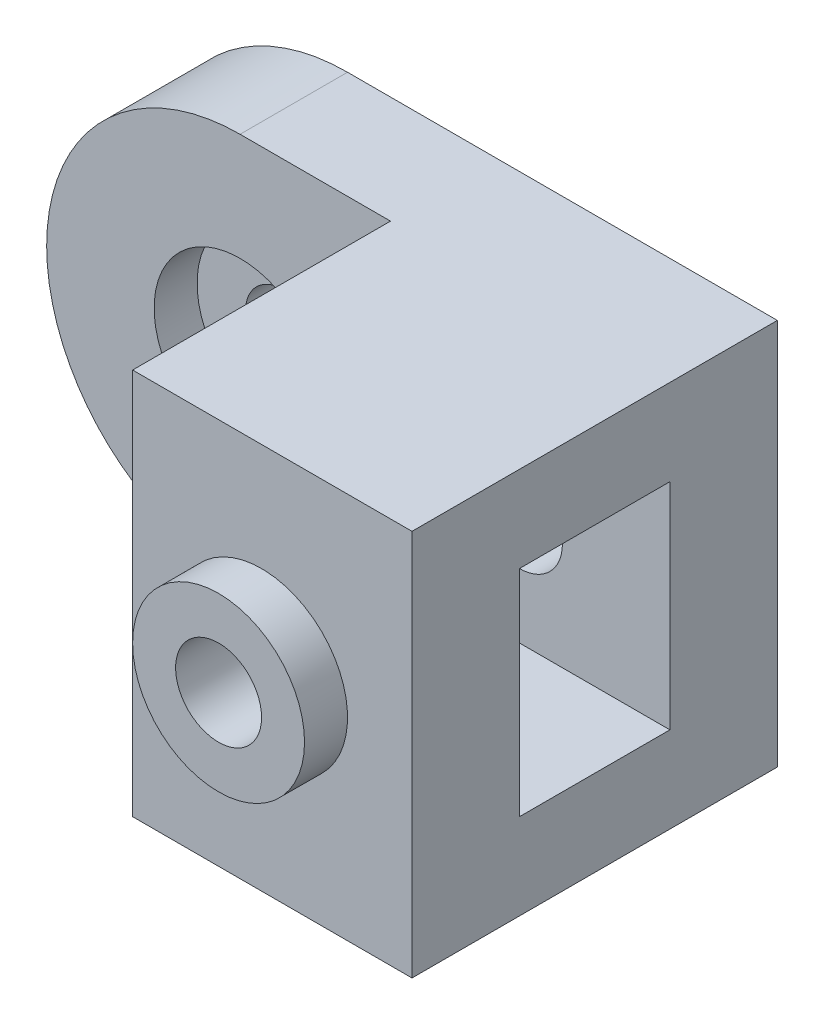
from build123d import *

# Parameters (mm, degrees)
SKETCH1_W                   = 145
SKETCH1_H                   = 90
BOSS_EXTRUDE1_DEPTH         = 85
CUT_EXTRUDE1_DEPTH          = 85
CUT_EXTRUDE3_DEPTH          = 50
M20_TAPPED_HOLE1_AT_2_COUNT = 2
M20_TAPPED_HOLE1_AT_2_PITCH = 65
M20_TAPPED_HOLE3_D          = 17.5
M20_TAPPED_HOLE3_DEPTH      = 60
M20_TAPPED_HOLE3_TIP        = 5.257530416
SKETCH12_R                  = 20
SKETCH12_R_2                = 10
CUT_EXTRUDE4_DEPTH          = 10
SKETCH13_R                  = 10
SKETCH13_R_2                = 8.75
CUT_EXTRUDE5_DEPTH          = 10
CUT_EXTRUDE6_DEPTH          = 10
SKETCH15_R                  = 20
SKETCH15_R_2                = 10
CUT_EXTRUDE7_DEPTH          = 10
SKETCH16_R                  = 10
SKETCH16_R_2                = 8.75
CUT_EXTRUDE8_DEPTH          = 10
SKETCH17_W                  = 35
SKETCH17_H                  = 50
CUT_EXTRUDE9_DEPTH          = 97
SKETCH18_R                  = 20
SKETCH18_R_2                = 10
BOSS_EXTRUDE2_DEPTH         = 10
SKETCH19_R                  = 20
SKETCH19_R_2                = 8.75
BOSS_EXTRUDE3_DEPTH         = 10
SKETCH20_R                  = 10
SKETCH20_R_2                = 8.75
CUT_EXTRUDE10_DEPTH         = 120


with BuildPart() as part:
    # Sketch1 → Boss-Extrude1 (new body)
    with BuildSketch(Plane.XY):
        with Locations((72.5, 45)):
            Rectangle(SKETCH1_W, SKETCH1_H)
    extrude(amount=BOSS_EXTRUDE1_DEPTH)

    # Sketch2 → Cut-Extrude1 (cut)
    with BuildSketch(Plane.XY.offset(85)):
        with BuildLine():
            ThreePointArc((0, 45), (13.180194847, 76.819805153), (45, 90))
            Line((45, 90), (0, 90))
            Line((0, 90), (0, 45))
        make_face()
        with BuildLine():
            ThreePointArc((45, 0), (13.180194847, 13.180194847), (0, 45))
            Line((0, 45), (0, 0))
            Line((0, 0), (45, 0))
        make_face()
    extrude(amount=-CUT_EXTRUDE1_DEPTH, mode=Mode.SUBTRACT)

    # Sketch4 → Cut-Extrude3 (cut)
    with BuildSketch(Plane.XY.offset(85)):
        with BuildLine():
            Line((80, 0), (80, 90))
            Line((80, 90), (45, 90))
            ThreePointArc((45, 90), (0, 45), (45, 0))
            Line((45, 0), (80, 0))
        make_face()
    extrude(amount=-CUT_EXTRUDE3_DEPTH, mode=Mode.SUBTRACT)

    # Sketch6 → M20 Tapped Hole1 (revolve, cut)
    with BuildSketch(Plane(origin=(45, 45, 35), x_dir=(0, -1, 0), z_dir=(1, 0, 0))):
        Polygon((0, 0), (0, 45.257530416), (8.75, 40), (8.75, 0), align=None)
    m20_tapped_hole1 = revolve(axis=Axis((45, 45, 41.35), (0, 0, -1)), mode=Mode.SUBTRACT)

    # M20 Tapped Hole1 at 2: M20 Tapped Hole1 ×2
    with Locations(*[(i * M20_TAPPED_HOLE1_AT_2_PITCH, 0, 0) for i in range(1, M20_TAPPED_HOLE1_AT_2_COUNT)]):
        add(m20_tapped_hole1, mode=Mode.SUBTRACT)

    # M20 Tapped Hole3
    with Locations(Plane(origin=(110, 45, 85), x_dir=(1, 0, 0), z_dir=(0, 0, 1))):
        with Locations((0, 0)):
            Hole(M20_TAPPED_HOLE3_D / 2, depth=M20_TAPPED_HOLE3_DEPTH)
            with Locations((0, 0, -(M20_TAPPED_HOLE3_DEPTH + M20_TAPPED_HOLE3_TIP / 2))):  # 118° drill point
                Cone(0, M20_TAPPED_HOLE3_D / 2, M20_TAPPED_HOLE3_TIP, mode=Mode.SUBTRACT)

    # Sketch12 → Cut-Extrude4 (cut)
    with BuildSketch(Plane.XY.offset(35)):
        with Locations((45, 45)):
            Circle(SKETCH12_R)
        with Locations((45, 45)):
            Circle(SKETCH12_R_2, mode=Mode.SUBTRACT)
    extrude(amount=-CUT_EXTRUDE4_DEPTH, mode=Mode.SUBTRACT)

    # Sketch13 → Cut-Extrude5 (cut)
    with BuildSketch(Plane.XY.offset(35)):
        with Locations((45, 45)):
            Circle(SKETCH13_R)
        with Locations((45, 45)):
            Circle(SKETCH13_R_2, mode=Mode.SUBTRACT)
    extrude(amount=-CUT_EXTRUDE5_DEPTH, mode=Mode.SUBTRACT)

    # Sketch14 → Cut-Extrude6 (cut)
    with BuildSketch(Plane.XY.offset(35)):
        with BuildLine():
            Line((80, 90), (80, 0))
            Line((80, 0), (45, 0))
            ThreePointArc((45, 0), (0, 45), (45, 90))
            Line((45, 90), (80, 90))
        make_face()
    extrude(amount=-CUT_EXTRUDE6_DEPTH, mode=Mode.SUBTRACT)

    # Sketch15 → Cut-Extrude7 (cut)
    with BuildSketch(Plane.XY.offset(25)):
        with Locations((45, 45)):
            Circle(SKETCH15_R)
        with Locations((45, 45)):
            Circle(SKETCH15_R_2, mode=Mode.SUBTRACT)
    extrude(amount=-CUT_EXTRUDE7_DEPTH, mode=Mode.SUBTRACT)

    # Sketch16 → Cut-Extrude8 (cut)
    with BuildSketch(Plane.XY.offset(25)):
        with Locations((45, 45)):
            Circle(SKETCH16_R)
        with Locations((45, 45)):
            Circle(SKETCH16_R_2, mode=Mode.SUBTRACT)
    extrude(amount=-CUT_EXTRUDE8_DEPTH, mode=Mode.SUBTRACT)

    # Sketch17 → Cut-Extrude9 (cut)
    with BuildSketch(Plane.ZY.offset(-80)):
        with Locations((42.5, 45)):
            Rectangle(SKETCH17_W, SKETCH17_H)
    extrude(amount=-CUT_EXTRUDE9_DEPTH, mode=Mode.SUBTRACT)

    # Sketch18 → Boss-Extrude2 (add)
    with BuildSketch(Plane.XY.offset(85)):
        with Locations((110, 45)):
            Circle(SKETCH18_R)
        with Locations((110, 45)):
            Circle(SKETCH18_R_2, mode=Mode.SUBTRACT)
    extrude(amount=BOSS_EXTRUDE2_DEPTH)

    # Sketch19 → Boss-Extrude3 (add)
    with BuildSketch(Plane(origin=(0, 0, 60), x_dir=(-1, 0, 0), z_dir=(0, 0, -1))):
        with Locations((-110, 45)):
            Circle(SKETCH19_R)
        with Locations((-110, 45)):
            Circle(SKETCH19_R_2, mode=Mode.SUBTRACT)
    extrude(amount=BOSS_EXTRUDE3_DEPTH)

    # Sketch20 → Cut-Extrude10 (cut)
    with BuildSketch(Plane.XY.offset(85)):
        with Locations((110, 45)):
            Circle(SKETCH20_R)
        with Locations((110, 45)):
            Circle(SKETCH20_R_2, mode=Mode.SUBTRACT)
    extrude(amount=-CUT_EXTRUDE10_DEPTH, mode=Mode.SUBTRACT)


solid = part.part
